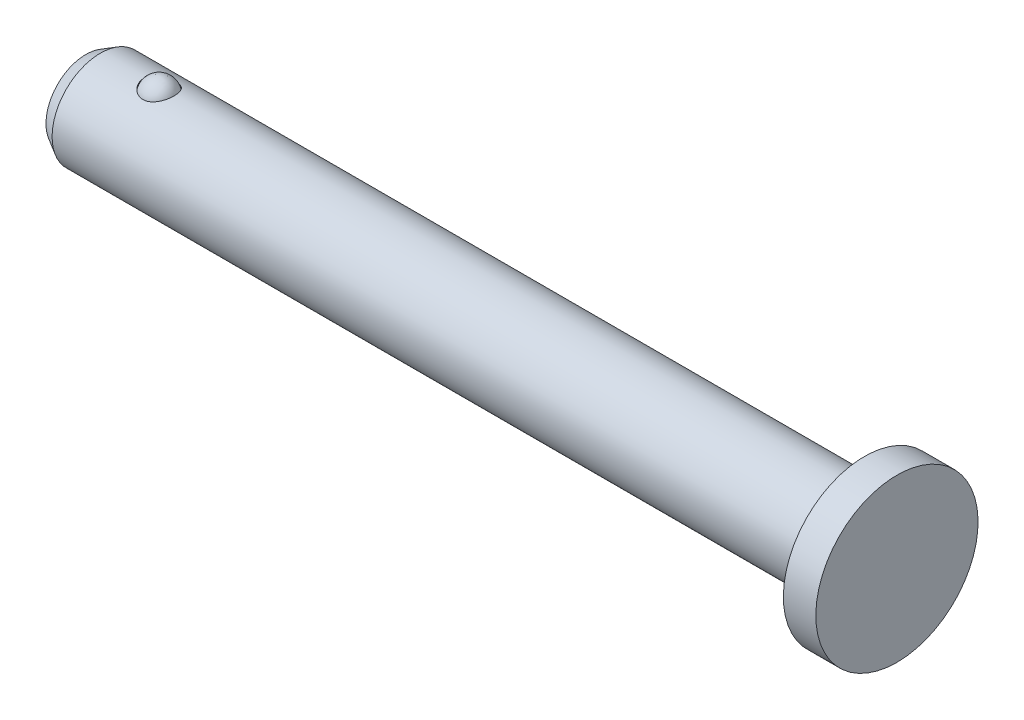
from build123d import *


with BuildPart() as part:
    # Sketch1 → Revolve1 (revolve)
    with BuildSketch(Plane.XY):
        Polygon((19.84375, 3.96875), (18.25625, 3.96875), (18.25625, 2.3622), (-19.13509, 2.3622), (-19.84375, 1.953054958), (-19.84375, 0), (19.84375, 0), align=None)
    revolve(axis=Axis((-19.84375, 0, 0), (1, 0, 0)))

    # Sketch2 → Cut-Revolve1 (revolve, cut)
    with BuildSketch(Plane.XY):
        with BuildLine():
            Line((-15.447407306, 2.029857306), (-17.077292694, 2.029857306))
            ThreePointArc((-17.077292694, 2.029857306), (-16.26235, 2.8448), (-15.447407306, 2.029857306))
        make_face()
    revolve(axis=Axis((-15.447407306, 2.029857306, 0), (1, 0, 0)), mode=Mode.SUBTRACT)


with BuildPart() as body_2:
    # Sketch3 → Revolve2 (revolve)
    with BuildSketch(Plane.XY):
        with BuildLine():
            Line((-15.472807306, 2.029857306), (-17.051892694, 2.029857306))
            ThreePointArc((-17.051892694, 2.029857306), (-16.26235, 2.8194), (-15.472807306, 2.029857306))
        make_face()
    revolve(axis=Axis((-15.472807306, 2.029857306, 0), (1, 0, 0)))


solid = Compound([part.part, body_2.part])
